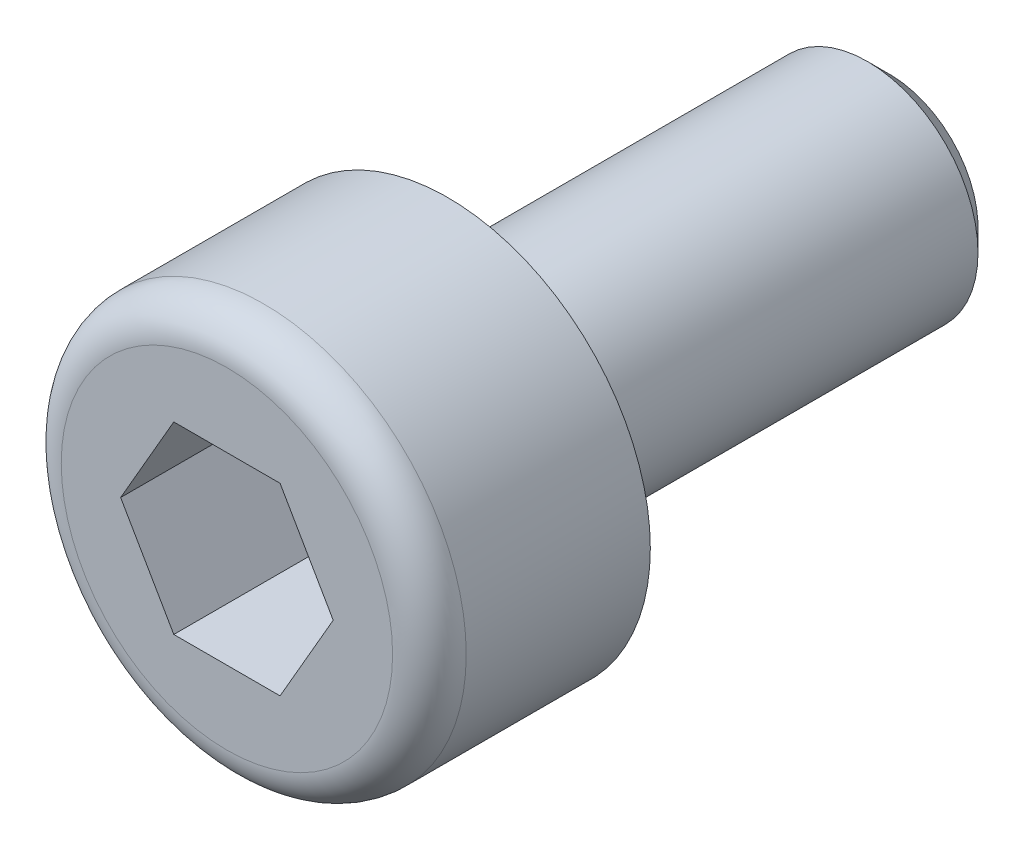
from build123d import *

# Parameters (mm, degrees)
SKICA1_R                 = 2.75
P_IDAT_VYSUNUT_M1_DEPTH  = 3
ODEBRAT_VYSUNUT_M1_DEPTH = 2
SKICA2_R                 = 1.5
P_IDAT_VYSUNUT_M2_DEPTH  = 6
ZKOSEN_1_SIZE            = 0.3
ZAOBLIT1_R               = 0.5


with BuildPart() as part:
    # Skica1 → Přidat vysunutím1 (new body)
    with BuildSketch(Plane.XY):
        Circle(SKICA1_R)
    extrude(amount=P_IDAT_VYSUNUT_M1_DEPTH)

    # Skica4 → Odebrat vysunutím1 (cut)
    with BuildSketch(Plane.XY.offset(3)):
        Polygon((-1.443375673, 0), (-0.721687836, -1.25), (0.721687836, -1.25), (1.443375673, 0), (0.721687836, 1.25), (-0.721687836, 1.25), align=None)
    extrude(amount=-ODEBRAT_VYSUNUT_M1_DEPTH, mode=Mode.SUBTRACT)

    # Skica2 → Přidat vysunutím2 (add)
    with BuildSketch(Plane(origin=(0, 0, 0), x_dir=(-1, 0, 0), z_dir=(0, 0, -1))):
        Circle(SKICA2_R)
    extrude(amount=P_IDAT_VYSUNUT_M2_DEPTH)

    # Zkosení1
    zkosen_1_edges = [part.edges().sort_by_distance(p)[0] for p in [
        (1.5, 0, -6),
    ]]
    chamfer(zkosen_1_edges, length=ZKOSEN_1_SIZE)

    # Zaoblit1
    zaoblit1_edges = [part.edges().sort_by_distance(p)[0] for p in [
        (-2.75, 0, 3),
    ]]
    fillet(zaoblit1_edges, radius=ZAOBLIT1_R)


solid = part.part
